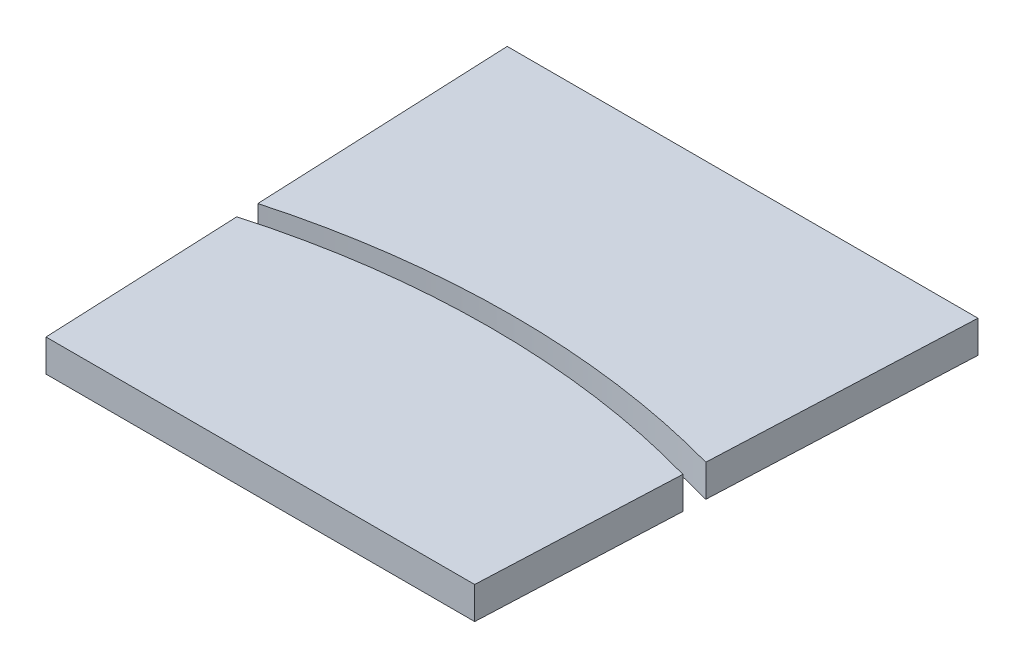
from build123d import *

# Parameters (mm, degrees)
BOSS_EXTRUDE1_DEPTH     = 3
CUT_EXTRUDE1_DEPTH      = 1
CUT_EXTRUDE1_DEPTH_BACK = 4


with BuildPart() as part:
    # Sketch1 → Boss-Extrude1 (new body)
    with BuildSketch(Plane(origin=(0, 0, 0), x_dir=(1, 0, 0), z_dir=(0, 1, 0))):
        Polygon((-21.964742431, 100), (-20, 55), (0, 55), (0, 100), align=None)
    boss_extrude1 = extrude(amount=BOSS_EXTRUDE1_DEPTH)

    # Mirror2: Boss-Extrude1 across plane
    add(boss_extrude1.mirror(Plane(origin=(0, 0, 0), x_dir=(0, 0, 1), z_dir=(1, 0, 0))))

    # Sketch2 → Cut-Extrude1 (cut, two sides)
    with BuildSketch(Plane(origin=(0, 3, 0), x_dir=(1, 0, 0), z_dir=(0, 1, 0))) as cut_extrude1_sk:
        with BuildLine():
            Line((-20.812722462, 73.61440473), (-20.902297167, 75.666002757))
            ThreePointArc((-20.902297167, 75.666002757), (0, 78.5), (20.902297167, 75.666002757))
            Line((20.902297167, 75.666002757), (20.812722462, 73.61440473))
            ThreePointArc((20.812722462, 73.61440473), (0, 76.5), (-20.812722462, 73.61440473))
        make_face()
    extrude(amount=CUT_EXTRUDE1_DEPTH, mode=Mode.SUBTRACT)
    extrude(cut_extrude1_sk.sketch, amount=-CUT_EXTRUDE1_DEPTH_BACK, mode=Mode.SUBTRACT)


solid = part.part
